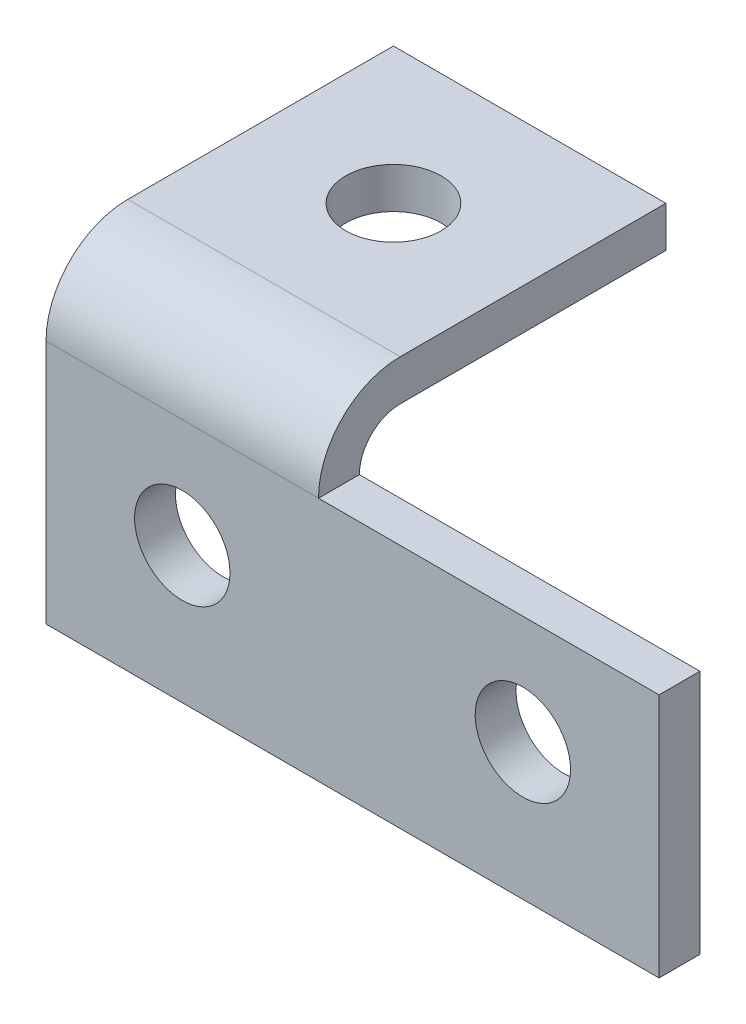
from build123d import *

# Parameters (mm, degrees)
BOSS_EXTRUDE1_DEPTH            = 40
CUT_EXTRUDE1_DEPTH             = 41
SKETCH3_W                      = 6
SKETCH3_H                      = 36
BOSS_EXTRUDE2_DEPTH            = 50
F_14_0_14_DIAMETER_HOLE1_D     = 14
F_14_0_14_DIAMETER_HOLE1_DEPTH = 51
F_14_0_14_DIAMETER_HOLE2_D     = 14
F_14_0_14_DIAMETER_HOLE2_DEPTH = 6
F_14_0_14_DIAMETER_HOLE3_D     = 14
F_14_0_14_DIAMETER_HOLE3_DEPTH = 6


with BuildPart() as part:
    # Sketch1 → Boss-Extrude1 (new body)
    with BuildSketch(Plane(origin=(-50, 0, 0), x_dir=(0, 0, -1), z_dir=(1, 0, 0))):
        with BuildLine():
            Line((0, 0), (51, 0))
            Line((51, 0), (51, 48))
            Line((51, 48), (12, 48))
            ThreePointArc((12, 48), (3.514718626, 44.485281374), (0, 36))
            Line((0, 36), (0, 0))
        make_face()
    extrude(amount=-BOSS_EXTRUDE1_DEPTH)

    # Sketch2 → Cut-Extrude1 (cut, through all)
    with BuildSketch(Plane.ZY.offset(90)):
        with BuildLine():
            Line((-51, 0), (-6, 0))
            Line((-6, 0), (-6, 36))
            ThreePointArc((-6, 36), (-7.757359313, 40.242640687), (-12, 42))
            Line((-12, 42), (-51, 42))
            Line((-51, 42), (-51, 0))
        make_face()
    extrude(amount=-CUT_EXTRUDE1_DEPTH, mode=Mode.SUBTRACT)

    # Sketch3 → Boss-Extrude2 (add)
    with BuildSketch(Plane(origin=(-50, 0, 0), x_dir=(0, 0, -1), z_dir=(1, 0, 0))):
        with Locations((3, 18)):
            Rectangle(SKETCH3_W, SKETCH3_H)
    extrude(amount=BOSS_EXTRUDE2_DEPTH)

    # Ø14.0 (14) Diameter Hole1
    with Locations(Plane.XY):
        with Locations((-70, 20)):
            Hole(F_14_0_14_DIAMETER_HOLE1_D / 2, depth=F_14_0_14_DIAMETER_HOLE1_DEPTH)

    # Ø14.0 (14) Diameter Hole2
    with Locations(Plane(origin=(0, 0, -6), x_dir=(-1, 0, 0), z_dir=(0, 0, -1))):
        with Locations((20, 20)):
            Hole(F_14_0_14_DIAMETER_HOLE2_D / 2, depth=F_14_0_14_DIAMETER_HOLE2_DEPTH)

    # Ø14.0 (14) Diameter Hole3
    with Locations(Plane(origin=(0, 42, 0), x_dir=(-1, 0, 0), z_dir=(0, -1, 0))):
        with Locations((70, 31)):
            Hole(F_14_0_14_DIAMETER_HOLE3_D / 2, depth=F_14_0_14_DIAMETER_HOLE3_DEPTH)


solid = part.part
